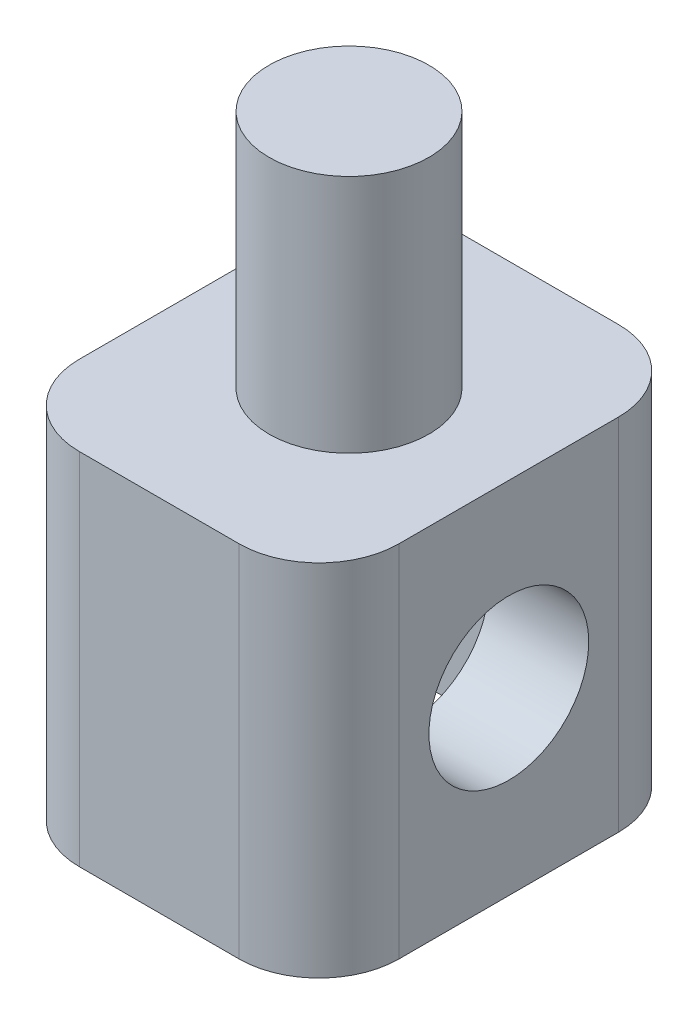
from build123d import *

# Parameters (mm, degrees)
SKETCH1_W           = 8
SKETCH1_H           = 9.5
BOSS_EXTRUDE1_DEPTH = 4.5
SKETCH2_R           = 2
BOSS_EXTRUDE2_DEPTH = 6
CUT_EXTRUDE1_DEPTH  = 1.5
SKETCH6_R           = 2
CUT_EXTRUDE2_DEPTH  = 9
FILLET1_R           = 2


with BuildPart() as part:
    # Sketch1 → Boss-Extrude1 (new body, symmetric)
    with BuildSketch(Plane(origin=(0, 0, 0), x_dir=(1, 0, 0), z_dir=(0, 1, 0))):
        Rectangle(SKETCH1_W, SKETCH1_H)
    extrude(amount=BOSS_EXTRUDE1_DEPTH, both=True)

    # Sketch2 → Boss-Extrude2 (add)
    with BuildSketch(Plane(origin=(0, 4.5, 0), x_dir=(1, 0, 0), z_dir=(0, 1, 0))):
        Circle(SKETCH2_R)
    extrude(amount=BOSS_EXTRUDE2_DEPTH)

    # Sketch5 → Cut-Extrude1 (cut, symmetric)
    with BuildSketch(Plane(origin=(0, 0, 0), x_dir=(0, 0, -1), z_dir=(1, 0, 0))):
        Polygon((-3.5, -2.020725942), (-3.5, -4.5), (3.5, -4.5), (3.5, -2.020725942), (3.5, 2.020725942), (0, 4.041451884), (-3.5, 2.020725942), align=None)
    extrude(amount=CUT_EXTRUDE1_DEPTH, both=True, mode=Mode.SUBTRACT)

    # Sketch6 → Cut-Extrude2 (cut, through all)
    with BuildSketch(Plane(origin=(4, 0, 0), x_dir=(0, 0, -1), z_dir=(1, 0, 0))):
        Circle(SKETCH6_R)
    extrude(amount=-CUT_EXTRUDE2_DEPTH, mode=Mode.SUBTRACT)

    # Fillet1
    fillet1_edges = [part.edges().sort_by_distance(p)[0] for p in [
        (-4, 0, -4.75),
        (4, 0, -4.75),
        (4, 0, 4.75),
        (-4, 0, 4.75),
    ]]
    fillet(fillet1_edges, radius=FILLET1_R)


solid = part.part
